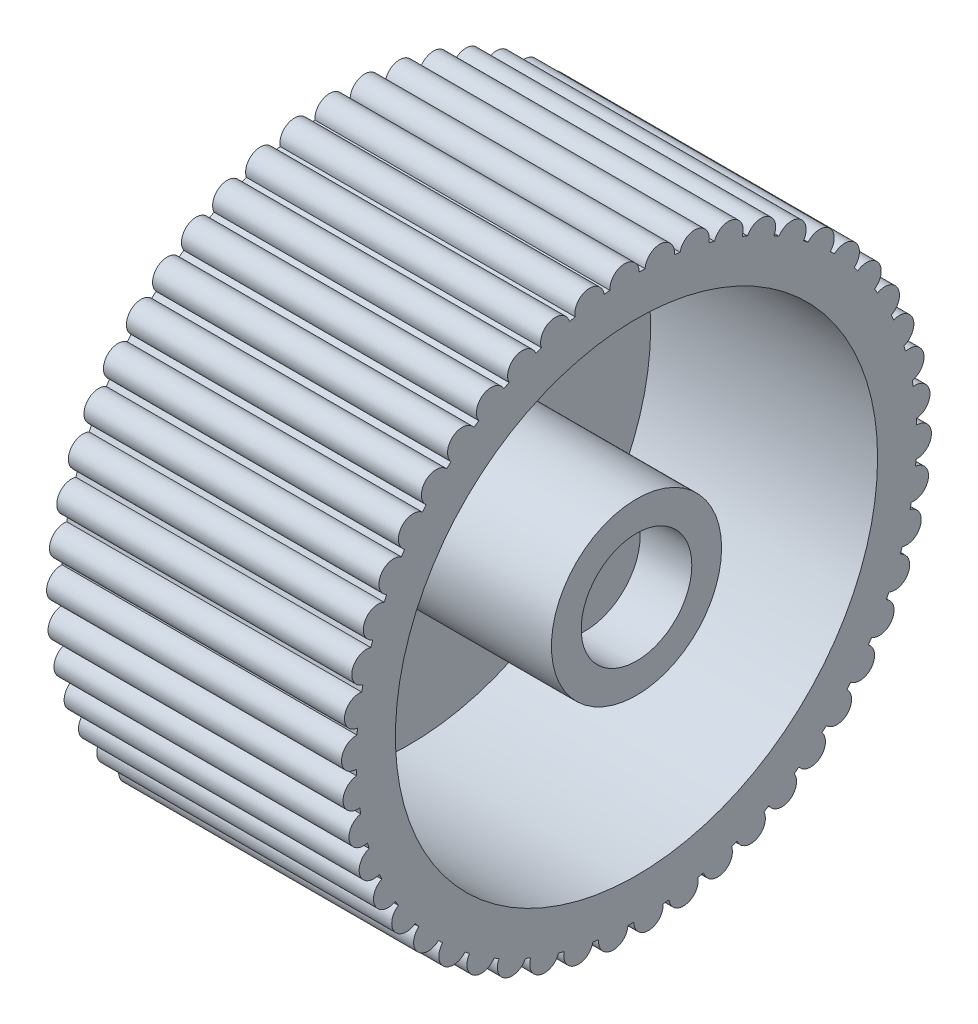
from build123d import *

# Parameters (mm, degrees)
SKETCH1_R           = 40
BOSS_EXTRUDE1_DEPTH = 40
SKETCH2_R           = 7.5
CUT_EXTRUDE1_DEPTH  = 7
CUT_EXTRUDE2_DEPTH  = 41
SCALE1_SCALE        = 1.3
SKETCH4_R           = 42.5
SKETCH4_R_2         = 15
CUT_EXTRUDE4_DEPTH  = 40


with BuildPart() as part:
    # Sketch1 → Boss-Extrude1 (new body)
    with BuildSketch(Plane(origin=(0, 0, 0), x_dir=(0, 0, -1), z_dir=(1, 0, 0))):
        Circle(SKETCH1_R)
    extrude(amount=BOSS_EXTRUDE1_DEPTH)

    # Sketch2 → Cut-Extrude1 (cut)
    with BuildSketch(Plane(origin=(40, 0, 0), x_dir=(0, 0, -1), z_dir=(1, 0, 0))):
        Circle(SKETCH2_R)
    extrude(amount=-CUT_EXTRUDE1_DEPTH, mode=Mode.SUBTRACT)

    # Sketch3 → Cut-Extrude2 (cut, through all)
    with BuildSketch(Plane.ZY):
        with BuildLine():
            ThreePointArc((-29.515783021, 23.933628071), (-30.214970301, 25.319377722), (-29.707020669, 26.786058369))
            ThreePointArc((-29.707020669, 26.786058369), (-31.33031117, 24.867882941), (-32.829955246, 22.851565341))
            ThreePointArc((-32.829955246, 22.851565341), (-31.516854991, 23.679171083), (-30.008571089, 23.312778925))
            ThreePointArc((-30.008571089, 23.312778925), (-29.763795902, 23.624488429), (-29.515783021, 23.933628071))
        make_face()
        with BuildLine():
            ThreePointArc((-26.283363259, 27.444212792), (-26.803356781, 28.906666332), (-26.115589332, 30.298118652))
            ThreePointArc((-26.115589332, 30.298118652), (-27.966490461, 28.598521138), (-29.707020669, 26.786058369))
            ThreePointArc((-29.707020669, 26.786058369), (-28.300548098, 27.442563094), (-26.850078577, 26.890021949))
            ThreePointArc((-26.850078577, 26.890021949), (-26.568165955, 27.168595065), (-26.283363259, 27.444212792))
        make_face()
        with BuildLine():
            ThreePointArc((-22.636439158, 30.521985883), (-22.969038261, 32.038080452), (-22.112298179, 33.332360691))
            ThreePointArc((-22.112298179, 33.332360691), (-24.161621213, 31.878143929), (-26.115589332, 30.298118652))
            ThreePointArc((-26.115589332, 30.298118652), (-24.637925116, 30.773169534), (-23.268144286, 30.043193264))
            ThreePointArc((-23.268144286, 30.043193264), (-22.95354016, 30.284236727), (-22.636439158, 30.521985883))
        make_face()
        with BuildLine():
            ThreePointArc((-18.632524888, 33.118409024), (-18.77248431, 34.664234467), (-17.760283534, 35.840930914))
            ThreePointArc((-17.760283534, 35.840930914), (-19.975708354, 34.655029588), (-22.112298179, 33.332360691))
            ThreePointArc((-22.112298179, 33.332360691), (-20.586746434, 33.618464628), (-19.31925746, 32.722565474))
            ThreePointArc((-19.31925746, 32.722565474), (-18.976923325, 32.922277885), (-18.632524888, 33.118409024))
        make_face()
        with BuildLine():
            ThreePointArc((-14.334764571, 35.192535071), (-14.279877167, 36.743712576), (-13.128179064, 37.784268081))
            ThreePointArc((-13.128179064, 37.784268081), (-15.474767212, 36.885384365), (-17.760283534, 35.840930914))
            ThreePointArc((-17.760283534, 35.840930914), (-16.210902898, 35.933576488), (-15.065694403, 34.885883279))
            ThreePointArc((-15.065694403, 34.885883279), (-14.701029073, 35.041115054), (-14.334764571, 35.192535071))
        make_face()
        with BuildLine():
            ThreePointArc((-9.810936453, 36.711653816), (-9.562067633, 38.24372081), (-8.289034488, 39.131725074))
            ThreePointArc((-8.289034488, 39.131725074), (-10.729779549, 38.534034707), (-13.128179064, 37.784268081))
            ThreePointArc((-13.128179064, 37.784268081), (-11.579403958, 37.681994487), (-10.574536346, 36.499029865))
            ThreePointArc((-10.574536346, 36.499029865), (-10.19329081, 36.607332906), (-9.810936453, 36.711653816))
        make_face()
        with BuildLine():
            ThreePointArc((-5.132384006, 37.651807851), (-4.693458983, 39.140602137), (-3.319168285, 39.86205115))
            ThreePointArc((-3.319168285, 39.86205115), (-5.815577095, 39.574980266), (-8.289034488, 39.131725074))
            ThreePointArc((-8.289034488, 39.131725074), (-6.765290485, 38.836144713), (-5.916611533, 37.536564946))
            ThreePointArc((-5.916611533, 37.536564946), (-5.524798262, 37.596231249), (-5.132384006, 37.651807851))
        make_face()
        with BuildLine():
            ThreePointArc((-3.319168285, 39.86205115), (-1.844484912, 39.377826158), (-1.165378223, 37.982125975))
            ThreePointArc((-1.165378223, 37.982125975), (-0.769176346, 37.992214568), (-0.372890798, 37.998170383))
            ThreePointArc((-0.372890798, 37.998170383), (0.249168951, 39.420213547), (1.703045156, 39.96372902))
            ThreePointArc((1.703045156, 39.96372902), (-0.809659243, 39.991804809), (-3.319168285, 39.86205115))
        make_face()
        with BuildLine():
            ThreePointArc((6.698399427, 39.43515494), (4.209027846, 39.777934645), (1.703045156, 39.96372902))
            ThreePointArc((1.703045156, 39.96372902), (3.105410032, 39.298495106), (3.604233799, 37.828686188))
            ThreePointArc((3.604233799, 37.828686188), (3.998575942, 37.789037967), (4.392483121, 37.745279069))
            ThreePointArc((4.392483121, 37.745279069), (5.187866973, 39.078144211), (6.698399427, 39.43515494))
        make_face()
        with BuildLine():
            ThreePointArc((11.588115989, 38.284664917), (9.16133551, 38.936742695), (6.698399427, 39.43515494))
            ThreePointArc((6.698399427, 39.43515494), (8.006330386, 38.599403693), (8.3170049, 37.078665422))
            ThreePointArc((8.3170049, 37.078665422), (8.703268298, 36.989905663), (9.088584957, 36.897122157))
            ThreePointArc((9.088584957, 36.897122157), (10.044749248, 38.119789218), (11.588115989, 38.284664917))
        make_face()
        with BuildLine():
            ThreePointArc((16.295080242, 36.530403227), (13.969163058, 37.481495214), (11.588115989, 38.284664917))
            ThreePointArc((11.588115989, 38.284664917), (12.780986148, 37.291576609), (12.898611866, 35.743891953))
            ThreePointArc((12.898611866, 35.743891953), (13.270704914, 35.60742045), (13.64135438, 35.467075587))
            ThreePointArc((13.64135438, 35.467075587), (14.743219418, 36.560262219), (16.295080242, 36.530403227))
        make_face()
        with BuildLine():
            ThreePointArc((20.745063071, 34.200034476), (18.556689058, 35.435142037), (16.295080242, 36.530403227))
            ThreePointArc((16.295080242, 36.530403227), (17.354077977, 35.395639499), (17.276800017, 33.845415955))
            ThreePointArc((17.276800017, 33.845415955), (17.628854585, 33.663384946), (17.978991494, 33.477692048))
            ThreePointArc((17.978991494, 33.477692048), (19.209181091, 34.424158393), (20.745063071, 34.200034476))
        make_face()
        with BuildLine():
            ThreePointArc((24.867882217, 31.330311745), (22.851564971, 32.829955504), (20.745063071, 34.200034476))
            ThreePointArc((20.745063071, 34.200034476), (21.653485952, 32.94149112), (21.382522712, 31.413177529))
            ThreePointArc((21.382522712, 31.413177529), (21.70898669, 31.188457751), (22.033089173, 30.960345307))
            ThreePointArc((22.033089173, 30.960345307), (23.372201573, 31.745164781), (24.867882217, 31.330311745))
        make_face()
        with BuildLine():
            ThreePointArc((28.598520821, 27.966490785), (26.786057685, 29.707021286), (24.867882217, 31.330311745))
            ThreePointArc((24.867882217, 31.330311745), (25.611405301, 29.967836684), (25.15103025, 28.485534528))
            ThreePointArc((25.15103025, 28.485534528), (25.446755105, 28.221669947), (25.739711873, 27.954735425))
            ThreePointArc((25.739711873, 27.954735425), (27.166628938, 28.565531076), (28.598520821, 27.966490785))
        make_face()
        with BuildLine():
            ThreePointArc((31.878144232, 24.161620813), (30.298118966, 26.115588968), (28.598520821, 27.966490785))
            ThreePointArc((28.598520821, 27.966490785), (29.165417595, 26.521571096), (28.522891016, 25.108657632))
            ThreePointArc((28.522891016, 25.108657632), (28.783212992, 24.809809549), (29.040403941, 24.508262666))
            ThreePointArc((29.040403941, 24.508262666), (30.532622799, 24.935401824), (31.878144232, 24.161620813))
        make_face()
        with BuildLine():
            ThreePointArc((34.655029121, 19.975709164), (33.33236045, 22.112298542), (31.878144232, 24.161620813))
            ThreePointArc((31.878144232, 24.161620813), (32.259473759, 22.657044026), (31.444928753, 21.335802205))
            ThreePointArc((31.444928753, 21.335802205), (31.665742415, 21.006683634), (31.883111491, 20.675279965))
            ThreePointArc((31.883111491, 20.675279965), (33.417098017, 20.912026508), (34.655029121, 19.975709164))
        make_face()
        with BuildLine():
            ThreePointArc((36.885384475, 15.474766948), (35.840930716, 17.760283934), (34.655029121, 19.975709164))
            ThreePointArc((34.655029121, 19.975709164), (34.844778897, 18.435202776), (33.871061178, 17.226468432))
            ThreePointArc((33.871061178, 17.226468432), (34.048884164, 16.872269769), (34.223003327, 16.516235748))
            ThreePointArc((34.223003327, 16.516235748), (35.774566587, 16.558855799), (36.885384475, 15.474766948))
        make_face()
        with BuildLine():
            ThreePointArc((38.534034744, 10.729779418), (37.784268228, 13.128178644), (36.885384475, 15.474766948))
            ThreePointArc((36.885384475, 15.474766948), (36.880560787, 13.922626423), (35.763026736, 12.845462961))
            ThreePointArc((35.763026736, 12.845462961), (35.895054671, 12.471770131), (36.023177956, 12.096720626))
            ThreePointArc((36.023177956, 12.096720626), (37.567848323, 11.9445422), (38.534034744, 10.729779418))
        make_face()
        with BuildLine():
            ThreePointArc((39.574980338, 5.815576606), (39.131725065, 8.289034529), (38.534034744, 10.729779418))
            ThreePointArc((38.534034744, 10.729779418), (38.334714375, 9.190482478), (37.090987998, 8.261876866))
            ThreePointArc((37.090987998, 8.261876866), (37.175138722, 7.874583227), (37.25524555, 7.486432995))
            ThreePointArc((37.25524555, 7.486432995), (38.768662764, 7.141855973), (39.574980338, 5.815576606))
        make_face()
        with BuildLine():
            ThreePointArc((39.991804799, 0.809659731), (39.862051192, 3.319167786), (39.574980338, 5.815576606))
            ThreePointArc((39.574980338, 5.815576606), (39.184306552, 4.31339902), (37.834002222, 3.547996038))
            ThreePointArc((37.834002222, 3.547996038), (37.868948628, 3.153209442), (37.899775667, 2.758079842))
            ThreePointArc((37.899775667, 2.758079842), (39.358071839, 2.22653876), (39.991804799, 0.809659731))
        make_face()
        with BuildLine():
            ThreePointArc((40, 0), (39.997951147, 0.404850603), (39.991804799, 0.809659731))
            ThreePointArc((39.991804799, 0.809659731), (39.415939168, -0.631708932), (37.98035163, -1.221838808))
            ThreePointArc((37.98035163, -1.221838808), (37.965542593, -1.617892339), (37.94660368, -2.013769877))
            ThreePointArc((37.94660368, -2.013769877), (39.326780978, -2.723892561), (39.777934749, -4.209026856))
            ThreePointArc((39.777934749, -4.209026856), (39.944445108, -2.107440394), (40, 0))
        make_face()
        with BuildLine():
            ThreePointArc((38.936742688, -9.16133554), (39.435155018, -6.698398963), (39.777934749, -4.209026856))
            ThreePointArc((39.777934749, -4.209026856), (39.025958604, -5.566854818), (37.527728204, -5.972404526))
            ThreePointArc((37.527728204, -5.972404526), (37.463397271, -6.363478992), (37.394991086, -6.753861242))
            ThreePointArc((37.394991086, -6.753861242), (38.675283559, -7.631366883), (38.936742688, -9.16133554))
        make_face()
        with BuildLine():
            ThreePointArc((37.481495377, -13.969162621), (38.284665044, -11.58811557), (38.936742688, -9.16133554))
            ThreePointArc((38.936742688, -9.16133554), (38.020514939, -10.414208335), (36.483270087, -10.628781856))
            ThreePointArc((36.483270087, -10.628781856), (36.370431795, -11.00870978), (36.253637144, -11.38744018))
            ThreePointArc((36.253637144, -11.38744018), (37.413853299, -12.418489181), (37.481495377, -13.969162621))
        make_face()
        with BuildLine():
            ThreePointArc((35.43514182, -18.556689473), (36.530403032, -16.295080679), (37.481495377, -13.969162621))
            ThreePointArc((37.481495377, -13.969162621), (36.415465865, -15.097323074), (34.863449007, -15.117536948))
            ThreePointArc((34.863449007, -15.117536948), (34.703882883, -15.480326638), (34.540541686, -15.841432385))
            ThreePointArc((34.540541686, -15.841432385), (35.562384637, -17.009765358), (35.43514182, -18.556689473))
        make_face()
        with BuildLine():
            ThreePointArc((32.82995523, -22.851565365), (34.200034481, -20.745063062), (35.43514182, -18.556689473))
            ThreePointArc((35.43514182, -18.556689473), (34.236122257, -19.542344398), (32.693810509, -19.367879451))
            ThreePointArc((32.693810509, -19.367879451), (32.490033007, -19.707809498), (32.282721253, -20.045595738))
            ThreePointArc((32.282721253, -20.045595738), (33.15007572, -21.332786952), (32.82995523, -22.851565365))
        make_face()
        with BuildLine():
            ThreePointArc((29.707020669, -26.786058369), (31.330311161, -24.867882953), (32.82995523, -22.851565365))
            ThreePointArc((32.82995523, -22.851565365), (31.516854977, -23.679171085), (30.008571089, -23.312778925))
            ThreePointArc((30.008571089, -23.312778925), (29.763795902, -23.624488429), (29.515783021, -23.933628071))
            ThreePointArc((29.515783021, -23.933628071), (30.214970301, -25.319377722), (29.707020669, -26.786058369))
        make_face()
        with BuildLine():
            ThreePointArc((26.115589356, -30.298118631), (27.966490472, -28.598521127), (29.707020669, -26.786058369))
            ThreePointArc((29.707020669, -26.786058369), (28.300548098, -27.442563094), (26.850078577, -26.890021949))
            ThreePointArc((26.850078577, -26.890021949), (26.568165955, -27.168595065), (26.283363259, -27.444212792))
            ThreePointArc((26.283363259, -27.444212792), (26.803356782, -28.906666317), (26.115589356, -30.298118631))
        make_face()
        with BuildLine():
            ThreePointArc((22.112298573, -33.33236043), (24.161621414, -31.878143777), (26.115589356, -30.298118631))
            ThreePointArc((26.115589356, -30.298118631), (24.637925131, -30.773169535), (23.268144286, -30.043193264))
            ThreePointArc((23.268144286, -30.043193264), (22.95354016, -30.284236727), (22.636439158, -30.521985883))
            ThreePointArc((22.636439158, -30.521985883), (22.969038305, -32.03808022), (22.112298573, -33.33236043))
        make_face()
        with BuildLine():
            ThreePointArc((17.760283563, -35.8409309), (19.975708573, -34.655029462), (22.112298573, -33.33236043))
            ThreePointArc((22.112298573, -33.33236043), (20.586746664, -33.618464678), (19.31925746, -32.722565474))
            ThreePointArc((19.31925746, -32.722565474), (18.976923325, -32.922277885), (18.632524888, -33.118409024))
            ThreePointArc((18.632524888, -33.118409024), (18.772484315, -34.664234452), (17.760283563, -35.8409309))
        make_face()
        with BuildLine():
            ThreePointArc((13.128178638, -37.784268229), (15.474767019, -36.885384446), (17.760283563, -35.8409309))
            ThreePointArc((17.760283563, -35.8409309), (16.210902913, -35.933576493), (15.065694403, -34.885883279))
            ThreePointArc((15.065694403, -34.885883279), (14.701029073, -35.041115054), (14.334764571, -35.192535071))
            ThreePointArc((14.334764571, -35.192535071), (14.279877072, -36.74371278), (13.128178638, -37.784268229))
        make_face()
        with BuildLine():
            ThreePointArc((8.289034488, -39.131725074), (10.729779332, -38.534034768), (13.128178638, -37.784268229))
            ThreePointArc((13.128178638, -37.784268229), (11.579403757, -37.681994386), (10.574536346, -36.499029865))
            ThreePointArc((10.574536346, -36.499029865), (10.19329081, -36.607332906), (9.810936453, -36.711653816))
            ThreePointArc((9.810936453, -36.711653816), (9.562067633, -38.24372081), (8.289034488, -39.131725074))
        make_face()
        with BuildLine():
            ThreePointArc((-32.282721253, 20.045595738), (-33.150075717, 21.332786938), (-32.829955246, 22.851565341))
            ThreePointArc((-32.829955246, 22.851565341), (-34.200034492, 20.745063045), (-35.435141826, 18.556689462))
            ThreePointArc((-35.435141826, 18.556689462), (-34.236122263, 19.542344397), (-32.693810509, 19.367879451))
            ThreePointArc((-32.693810509, 19.367879451), (-32.490033007, 19.707809498), (-32.282721253, 20.045595738))
        make_face()
        with BuildLine():
            ThreePointArc((-34.540541686, 15.841432385), (-35.562384635, 17.009765352), (-35.435141826, 18.556689462))
            ThreePointArc((-35.435141826, 18.556689462), (-36.530402939, 16.295080888), (-37.481495212, 13.969163062))
            ThreePointArc((-37.481495212, 13.969163062), (-36.415465649, 15.097323169), (-34.863449007, 15.117536948))
            ThreePointArc((-34.863449007, 15.117536948), (-34.703882883, 15.480326638), (-34.540541686, 15.841432385))
        make_face()
        with BuildLine():
            ThreePointArc((-36.253637144, 11.38744018), (-37.4138534, 12.418489394), (-37.481495212, 13.969163062))
            ThreePointArc((-37.481495212, 13.969163062), (-38.284664973, 11.588115805), (-38.936742683, 9.161335559))
            ThreePointArc((-38.936742683, 9.161335559), (-38.02051493, 10.41420834), (-36.483270087, 10.628781856))
            ThreePointArc((-36.483270087, 10.628781856), (-36.370431795, 11.00870978), (-36.253637144, 11.38744018))
        make_face()
        with BuildLine():
            ThreePointArc((-37.394991086, 6.753861242), (-38.675283565, 7.631366891), (-38.936742683, 9.161335559))
            ThreePointArc((-38.936742683, 9.161335559), (-39.435155018, 6.698398966), (-39.777934751, 4.209026843))
            ThreePointArc((-39.777934751, 4.209026843), (-39.025958609, 5.566854814), (-37.527728204, 5.972404526))
            ThreePointArc((-37.527728204, 5.972404526), (-37.463397271, 6.363478992), (-37.394991086, 6.753861242))
        make_face()
        with BuildLine():
            ThreePointArc((-37.94660368, 2.013769877), (-39.326780974, 2.723892556), (-39.777934751, 4.209026843))
            ThreePointArc((-39.777934751, 4.209026843), (-39.963729066, 1.70304409), (-39.991804798, -0.8096598))
            ThreePointArc((-39.991804798, -0.8096598), (-39.415939192, 0.631708907), (-37.98035163, 1.221838808))
            ThreePointArc((-37.98035163, 1.221838808), (-37.965542593, 1.617892339), (-37.94660368, 2.013769877))
        make_face()
        with BuildLine():
            ThreePointArc((-37.899775667, -2.758079842), (-39.358071813, -2.226538783), (-39.991804798, -0.8096598))
            ThreePointArc((-39.991804798, -0.8096598), (-39.862051187, -3.319167843), (-39.574980331, -5.815576651))
            ThreePointArc((-39.574980331, -5.815576651), (-39.184306566, -4.313399038), (-37.834002222, -3.547996038))
            ThreePointArc((-37.834002222, -3.547996038), (-37.868948628, -3.153209442), (-37.899775667, -2.758079842))
        make_face()
        with BuildLine():
            ThreePointArc((-37.25524555, -7.486432995), (-38.768662746, -7.141855986), (-39.574980331, -5.815576651))
            ThreePointArc((-39.574980331, -5.815576651), (-39.131725057, -8.289034565), (-38.534034736, -10.729779446))
            ThreePointArc((-38.534034736, -10.729779446), (-38.334714382, -9.19048249), (-37.090987998, -8.261876866))
            ThreePointArc((-37.090987998, -8.261876866), (-37.175138722, -7.874583227), (-37.25524555, -7.486432995))
        make_face()
        with BuildLine():
            ThreePointArc((-36.023177956, -12.096720626), (-37.567848311, -11.944542207), (-38.534034736, -10.729779446))
            ThreePointArc((-38.534034736, -10.729779446), (-37.784268062, -13.12817912), (-36.885384096, -15.474767852))
            ThreePointArc((-36.885384096, -15.474767852), (-36.880560979, -13.922626874), (-35.763026736, -12.845462961))
            ThreePointArc((-35.763026736, -12.845462961), (-35.895054671, -12.471770131), (-36.023177956, -12.096720626))
        make_face()
        with BuildLine():
            ThreePointArc((-34.223003327, -16.516235748), (-35.774566131, -16.558855978), (-36.885384096, -15.474767852))
            ThreePointArc((-36.885384096, -15.474767852), (-35.840930496, -17.760284378), (-34.655029115, -19.975709175))
            ThreePointArc((-34.655029115, -19.975709175), (-34.844778899, -18.435202782), (-33.871061178, -17.226468432))
            ThreePointArc((-33.871061178, -17.226468432), (-34.048884164, -16.872269769), (-34.223003327, -16.516235748))
        make_face()
        with BuildLine():
            ThreePointArc((-31.883111491, -20.675279965), (-33.417098011, -20.912026509), (-34.655029115, -19.975709175))
            ThreePointArc((-34.655029115, -19.975709175), (-33.332360312, -22.112298751), (-31.878143936, -24.161621203))
            ThreePointArc((-31.878143936, -24.161621203), (-32.259473796, -22.657044268), (-31.444928753, -21.335802205))
            ThreePointArc((-31.444928753, -21.335802205), (-31.665742415, -21.006683634), (-31.883111491, -20.675279965))
        make_face()
        with BuildLine():
            ThreePointArc((-29.040403941, -24.508262666), (-30.532622556, -24.935401854), (-31.878143936, -24.161621203))
            ThreePointArc((-31.878143936, -24.161621203), (-30.298118793, -26.115589168), (-28.598520794, -27.966490813))
            ThreePointArc((-28.598520794, -27.966490813), (-29.165417595, -26.521571116), (-28.522891016, -25.108657632))
            ThreePointArc((-28.522891016, -25.108657632), (-28.783212992, -24.809809549), (-29.040403941, -24.508262666))
        make_face()
        with BuildLine():
            ThreePointArc((-25.739711873, -27.954735425), (-27.166628918, -28.565531076), (-28.598520794, -27.966490813))
            ThreePointArc((-28.598520794, -27.966490813), (-26.786057673, -29.707021297), (-24.867882223, -31.33031174))
            ThreePointArc((-24.867882223, -31.33031174), (-25.611405301, -29.96783668), (-25.15103025, -28.485534528))
            ThreePointArc((-25.15103025, -28.485534528), (-25.446755105, -28.221669947), (-25.739711873, -27.954735425))
        make_face()
        with BuildLine():
            ThreePointArc((-22.033089173, -30.960345307), (-23.372201577, -31.745164781), (-24.867882223, -31.33031174))
            ThreePointArc((-24.867882223, -31.33031174), (-22.85156458, -32.829955776), (-20.745062252, -34.200034973))
            ThreePointArc((-20.745062252, -34.200034973), (-21.653485845, -32.941491587), (-21.382522712, -31.413177529))
            ThreePointArc((-21.382522712, -31.413177529), (-21.70898669, -31.188457751), (-22.033089173, -30.960345307))
        make_face()
        with BuildLine():
            ThreePointArc((-17.978991494, -33.477692048), (-19.209180628, -34.424158272), (-20.745062252, -34.200034973))
            ThreePointArc((-20.745062252, -34.200034973), (-18.556688849, -35.435142147), (-16.295080686, -36.530403029))
            ThreePointArc((-16.295080686, -36.530403029), (-17.354078061, -35.395639271), (-17.276800017, -33.845415955))
            ThreePointArc((-17.276800017, -33.845415955), (-17.628854585, -33.663384946), (-17.978991494, -33.477692048))
        make_face()
        with BuildLine():
            ThreePointArc((-13.64135438, -35.467075587), (-14.743219644, -36.560262309), (-16.295080686, -36.530403029))
            ThreePointArc((-16.295080686, -36.530403029), (-13.969163265, -37.481495137), (-11.588115946, -38.28466493))
            ThreePointArc((-11.588115946, -38.28466493), (-12.780986137, -37.291576628), (-12.898611866, -35.743891953))
            ThreePointArc((-12.898611866, -35.743891953), (-13.270704914, -35.60742045), (-13.64135438, -35.467075587))
        make_face()
        with BuildLine():
            ThreePointArc((-9.088584957, -36.897122157), (-10.044749229, -38.119789207), (-11.588115946, -38.28466493))
            ThreePointArc((-11.588115946, -38.28466493), (-9.161335263, -38.936742753), (-6.69839897, -39.435155017))
            ThreePointArc((-6.69839897, -39.435155017), (-8.006330255, -38.599403884), (-8.3170049, -37.078665422))
            ThreePointArc((-8.3170049, -37.078665422), (-8.703268298, -36.989905663), (-9.088584957, -36.897122157))
        make_face()
        with BuildLine():
            ThreePointArc((-4.392483121, -37.745279069), (-5.187866786, -39.078144074), (-6.69839897, -39.435155017))
            ThreePointArc((-6.69839897, -39.435155017), (-4.209027091, -39.777934725), (-1.703044102, -39.963729065))
            ThreePointArc((-1.703044102, -39.963729065), (-3.105409681, -39.2984955), (-3.604233799, -37.828686188))
            ThreePointArc((-3.604233799, -37.828686188), (-3.998575942, -37.789037967), (-4.392483121, -37.745279069))
        make_face()
        with BuildLine():
            ThreePointArc((0.372890798, -37.998170383), (-0.249168568, -39.420213184), (-1.703044102, -39.963729065))
            ThreePointArc((-1.703044102, -39.963729065), (0.809659805, -39.991804798), (3.319168354, -39.862051144))
            ThreePointArc((3.319168354, -39.862051144), (1.844484938, -39.377826181), (1.165378223, -37.982125975))
            ThreePointArc((1.165378223, -37.982125975), (0.769176346, -37.992214568), (0.372890798, -37.998170383))
        make_face()
        with BuildLine():
            ThreePointArc((3.319168354, -39.862051144), (5.815577129, -39.574980261), (8.289034488, -39.131725074))
            ThreePointArc((8.289034488, -39.131725074), (6.765290485, -38.836144713), (5.916611533, -37.536564946))
            ThreePointArc((5.916611533, -37.536564946), (5.524798262, -37.596231249), (5.132384006, -37.651807851))
            ThreePointArc((5.132384006, -37.651807851), (4.693459005, -39.14060211), (3.319168354, -39.862051144))
        make_face()
    extrude(amount=-CUT_EXTRUDE2_DEPTH, mode=Mode.SUBTRACT)


with BuildPart() as part_1:
    # Scale1: scaled about (19.894183686, 0, 0)
    add(part.part.scale(SCALE1_SCALE).moved(Location((-5.968255106, 0, 0))))

    # Sketch4 → Cut-Extrude4 (cut)
    with BuildSketch(Plane(origin=(46.031744894, 0, 0), x_dir=(0, 0, -1), z_dir=(1, 0, 0))):
        Circle(SKETCH4_R)
        Circle(SKETCH4_R_2, mode=Mode.SUBTRACT)
    extrude(amount=-CUT_EXTRUDE4_DEPTH, mode=Mode.SUBTRACT)


solid = part_1.part
